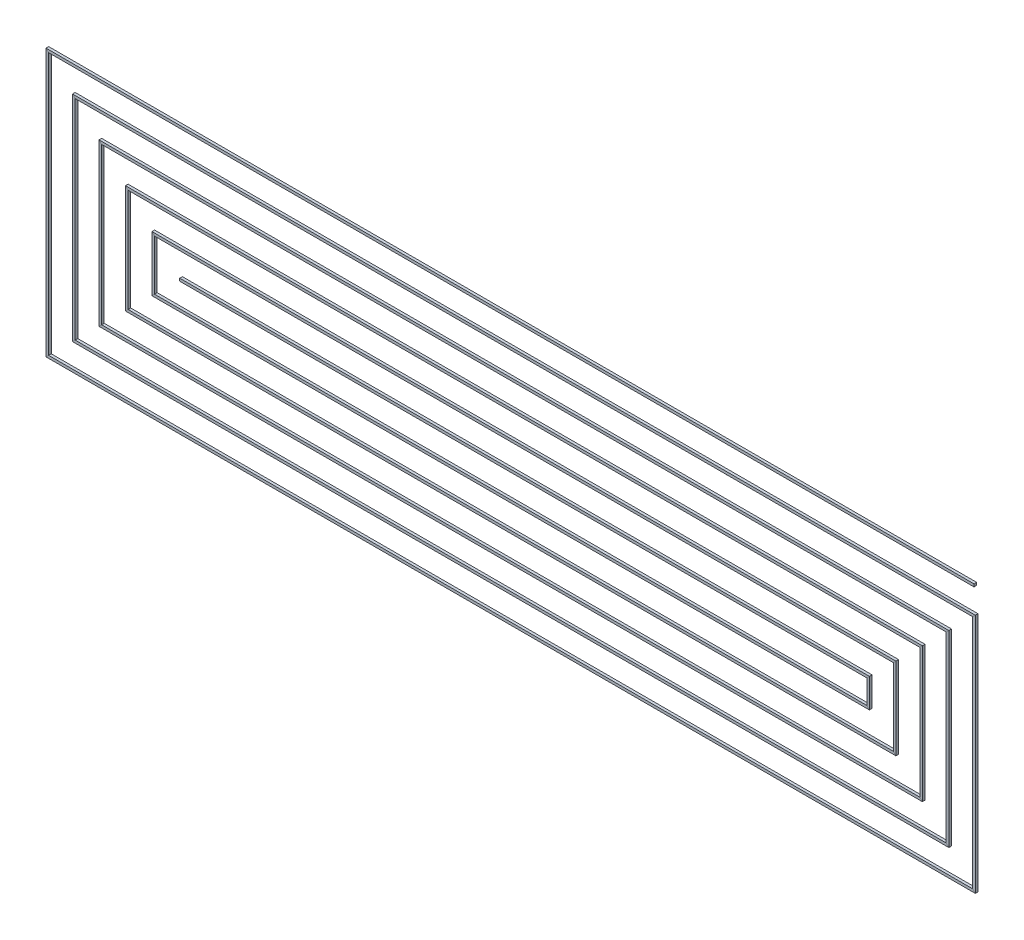
from build123d import *

# Parameters (mm, degrees)
SKETCH4_W = 0.2
SKETCH4_H = 0.2


with BuildPart() as part:
    # Sweep2: sweep along a path in Sketch3
    with BuildLine(Plane.XY) as sweep2_path:
        Line((35, 10), (-35, 10))
        Line((-35, 10), (-35, -10))
        Line((-35, -10), (35, -10))
        Line((35, -10), (35, 8))
        Line((35, 8), (-33, 8))
        Line((-33, 8), (-33, -8))
        Line((-33, -8), (33, -8))
        Line((33, -8), (33, 6))
        Line((33, 6), (-31, 6))
        Line((-31, 6), (-31, -6))
        Line((-31, -6), (31, -6))
        Line((31, -6), (31, 4))
        Line((31, 4), (-29, 4))
        Line((-29, 4), (-29, -4))
        Line((-29, -4), (29, -4))
        Line((29, -4), (29, 2))
        Line((29, 2), (-27, 2))
        Line((-27, 2), (-27, -2))
        Line((-27, -2), (27, -2))
        Line((27, -2), (27, 0))
        Line((27, 0), (-25, 0))
    # Sketch4 → Sweep2 (sweep)
    with BuildSketch(Plane(origin=(0, 0, 0), x_dir=(0, 0, -1), z_dir=(1, 0, 0))):
        Rectangle(SKETCH4_W, SKETCH4_H)
    sweep(path=sweep2_path.line, transition=Transition.RIGHT)


solid = part.part
